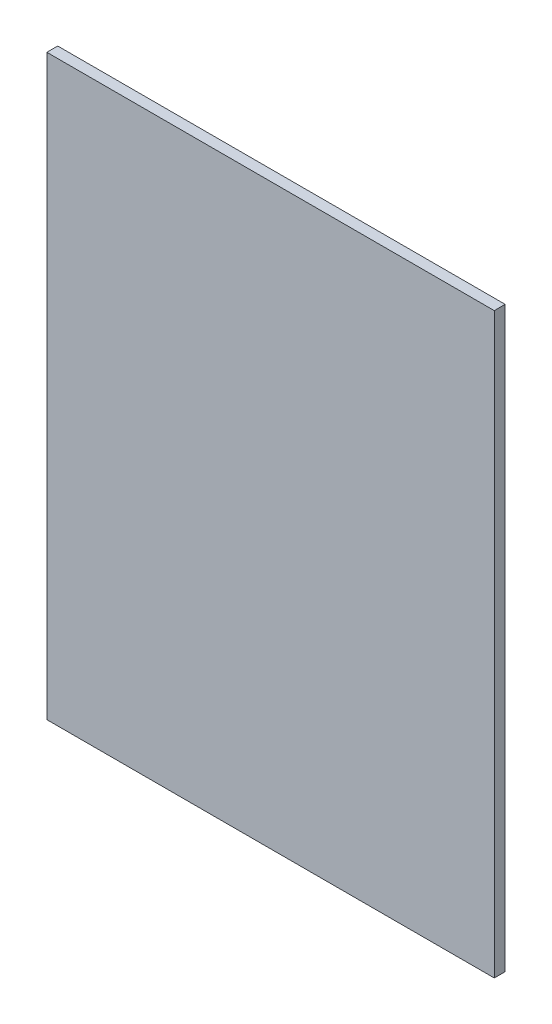
from build123d import *

# Parameters (mm, degrees)
SKETCH1_W      = 658
SKETCH1_H      = 850
EXTRUDE1_DEPTH = 16


with BuildPart() as part:
    # Sketch1 → Extrude1 (new body)
    with BuildSketch(Plane.XY):
        with Locations((329, 425)):
            Rectangle(SKETCH1_W, SKETCH1_H)
    extrude(amount=EXTRUDE1_DEPTH)


solid = part.part
